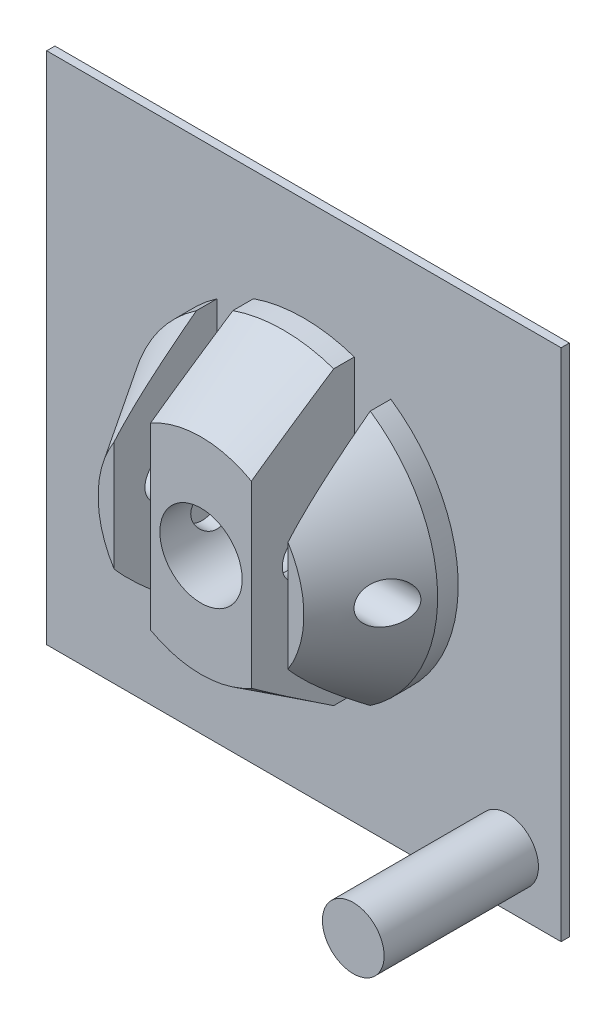
from build123d import *

# Parameters (mm, degrees)
CROQUIS1_W              = 50
CROQUIS1_H              = 50
CROQUIS1_R              = 2
SALIENTE_EXTRUIR2_DEPTH = 0.8
CROQUIS4_R              = 4
CROQUIS4_W              = 3.55
CROQUIS4_H              = 40
CORTAR_EXTRUIR1_DEPTH   = 10
CORTAR_EXTRUIR2_START   = -39.374993
CROQUIS7_R              = 2
CORTAR_EXTRUIR2_DEPTH   = 28.749989
CROQUIS8_R              = 3
SALIENTE_EXTRUIR3_DEPTH = 15


with BuildPart() as part:
    # Croquis1 → Saliente-Extruir2 (new body)
    with BuildSketch(Plane.XY):
        Rectangle(CROQUIS1_W, CROQUIS1_H)
        Circle(CROQUIS1_R, mode=Mode.SUBTRACT)
    extrude(amount=SALIENTE_EXTRUIR2_DEPTH)

    # Croquis2 → Revolución1 (revolve)
    with BuildSketch(Plane(origin=(0, 0, 0), x_dir=(0, 0, -1), z_dir=(1, 0, 0))):
        Polygon((-0.8, 0), (-10.8, 0), (-10.8, 10), (-2.8, 15), (-0.8, 15), align=None)
    revolve(axis=Axis((0, 0, 0.8), (0, 0, 1)))

    # Croquis4 → Cortar-Extruir1 (cut)
    with BuildSketch(Plane.XY.offset(10.8)):
        Circle(CROQUIS4_R)
        with Locations((-6.675, 0)):
            Rectangle(CROQUIS4_W, CROQUIS4_H)
        with Locations((6.675, 0)):
            Rectangle(CROQUIS4_W, CROQUIS4_H)
    extrude(amount=-CORTAR_EXTRUIR1_DEPTH, mode=Mode.SUBTRACT)

    # Croquis7 → Cortar-Extruir2 (cut)
    with BuildSketch(Plane.ZY.offset(25).offset(CORTAR_EXTRUIR2_START)):
        with Locations((5.8, 0)):
            Circle(CROQUIS7_R)
    extrude(amount=CORTAR_EXTRUIR2_DEPTH, mode=Mode.SUBTRACT)

    # Croquis8 → Saliente-Extruir3 (add)
    with BuildSketch(Plane.XY.offset(0.8)):
        with Locations((19.8, -19.8)):
            Circle(CROQUIS8_R)
    extrude(amount=SALIENTE_EXTRUIR3_DEPTH)


solid = part.part
